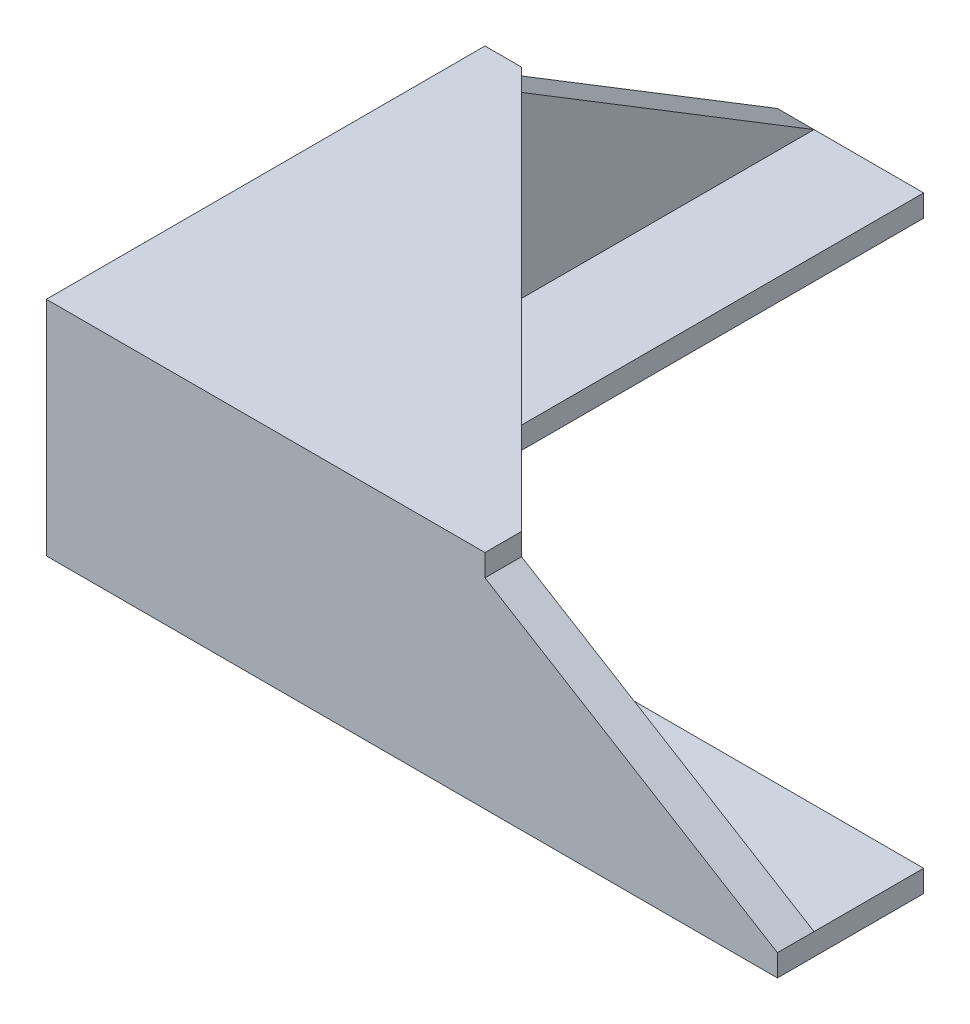
from build123d import *

# Parameters (mm, degrees)
BOSS_EXTRUDE1_DEPTH = 3
BOSS_EXTRUDE2_DEPTH = 24.4
BOSS_EXTRUDE3_DEPTH = 3
CUT_EXTRUDE2_DEPTH  = 101
CUT_EXTRUDE3_DEPTH  = 101


with BuildPart() as part:
    # Sketch1 → Boss-Extrude1 (new body)
    with BuildSketch(Plane(origin=(0, 0, 0), x_dir=(1, 0, 0), z_dir=(0, 1, 0))):
        Polygon((0, 0), (0, 100), (20, 100), (20, 20), (100, 20), (100, 0), align=None)
    extrude(amount=BOSS_EXTRUDE1_DEPTH)

    # Sketch2 → Boss-Extrude2 (add)
    with BuildSketch(Plane(origin=(0, 3, 0), x_dir=(1, 0, 0), z_dir=(0, 1, 0))):
        Polygon((0, 100), (0, 0), (100, 0), (100, 5), (5, 5), (5, 100), align=None)
    extrude(amount=BOSS_EXTRUDE2_DEPTH)

    # Sketch3 → Boss-Extrude3 (add)
    with BuildSketch(Plane(origin=(0, 27.4, 0), x_dir=(1, 0, 0), z_dir=(0, 1, 0))):
        Polygon((0, 0), (0, 60), (5, 60), (60, 5), (60, 0), align=None)
    extrude(amount=BOSS_EXTRUDE3_DEPTH)

    # Sketch4 → Cut-Extrude2 (cut, through all)
    with BuildSketch(Plane.ZY):
        Polygon((-60, 27.4), (-100, 3), (-100, 27.4), align=None)
    extrude(amount=-CUT_EXTRUDE2_DEPTH, mode=Mode.SUBTRACT)

    # Sketch5 → Cut-Extrude3 (cut, through all)
    with BuildSketch(Plane.XY):
        Polygon((60, 27.4), (100, 3), (100, 27.4), align=None)
    extrude(amount=-CUT_EXTRUDE3_DEPTH, mode=Mode.SUBTRACT)


solid = part.part
